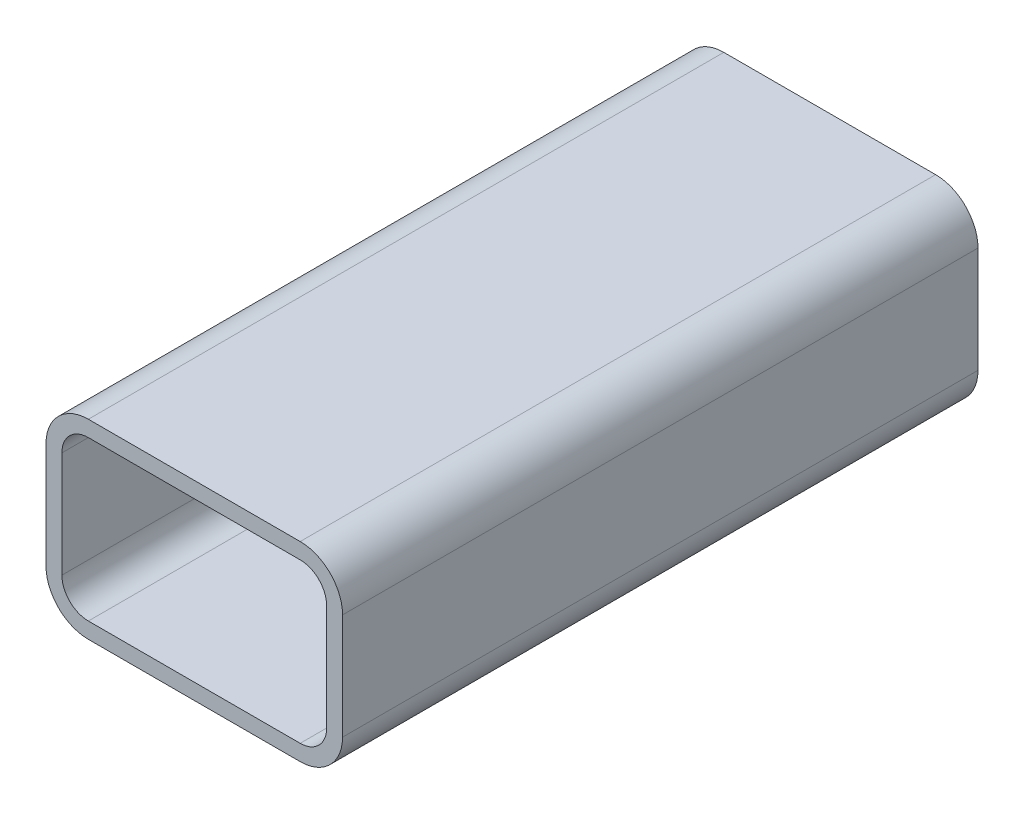
from build123d import *

# Parameters (mm, degrees)
EXTRUDE_THIN1_DEPTH = 60


with BuildPart() as part:
    # Sketch1 → Extrude-Thin1 (new body, symmetric)
    with BuildSketch(Plane.XY):
        with BuildLine():
            Line((-20, 18), (20, 18))
            ThreePointArc((20, 18), (25.656854249, 15.656854249), (28, 10))
            Line((28, 10), (28, -10))
            ThreePointArc((28, -10), (25.656854249, -15.656854249), (20, -18))
            Line((20, -18), (-20, -18))
            ThreePointArc((-20, -18), (-25.656854249, -15.656854249), (-28, -10))
            Line((-28, -10), (-28, 10))
            ThreePointArc((-28, 10), (-25.656854249, 15.656854249), (-20, 18))
        make_face()
        with BuildLine():
            Line((-20, 15), (20, 15))
            ThreePointArc((20, 15), (23.535533906, 13.535533906), (25, 10))
            Line((25, 10), (25, -10))
            ThreePointArc((25, -10), (23.535533906, -13.535533906), (20, -15))
            Line((20, -15), (-20, -15))
            ThreePointArc((-20, -15), (-23.535533906, -13.535533906), (-25, -10))
            Line((-25, -10), (-25, 10))
            ThreePointArc((-25, 10), (-23.535533906, 13.535533906), (-20, 15))
        make_face(mode=Mode.SUBTRACT)
    extrude(amount=EXTRUDE_THIN1_DEPTH, both=True)


solid = part.part
